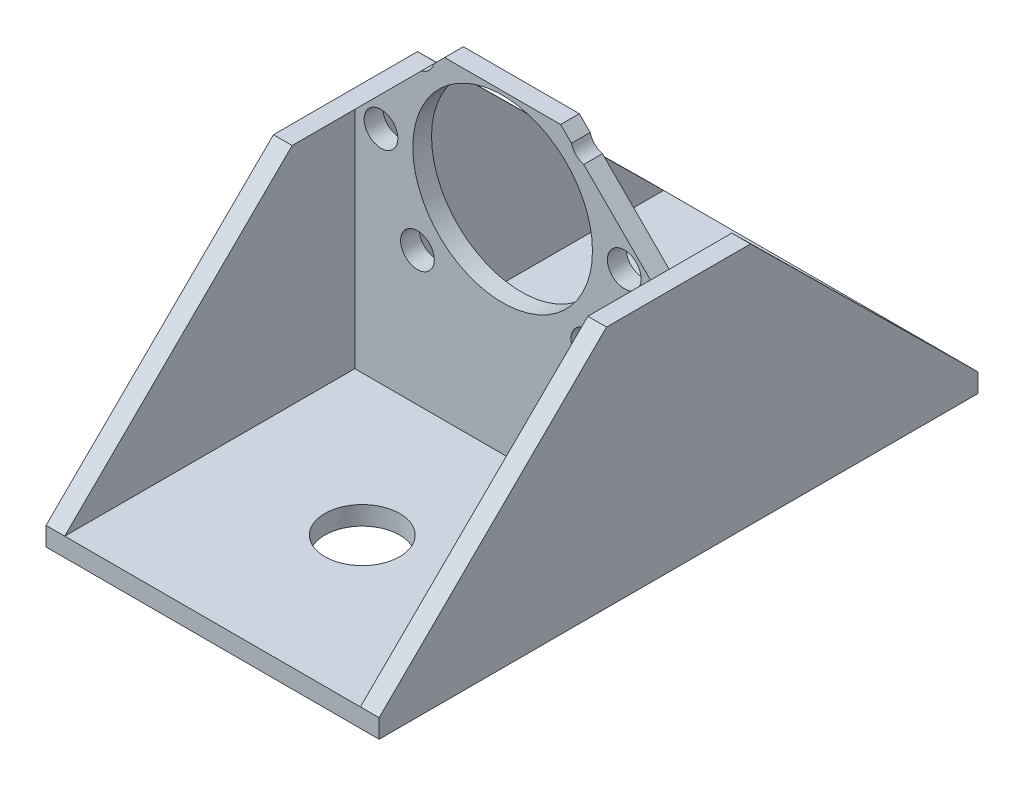
from build123d import *

# Parameters (mm, degrees)
CROQUIS1_W                   = 44.5
CROQUIS1_H                   = 44.5
CROQUIS1_W_2                 = 39.5
CROQUIS1_H_2                 = 39.5
SALIENTE_EXTRUIR1_DEPTH      = 40
SALIENTE_EXTRUIR1_DEPTH_BACK = 40
CORTAR_EXTRUIR1_DEPTH        = 44.5
SALIENTE_EXTRUIR2_DEPTH      = 1.25
SALIENTE_EXTRUIR2_DEPTH_BACK = 1.25
CROQUIS4_R                   = 5
CORTAR_EXTRUIR2_DEPTH        = 2.5
CROQUIS7_R                   = 12
CORTAR_EXTRUIR5_DEPTH        = 2.5
CROQUIS8_R                   = 2.25
CORTAR_EXTRUIR6_DEPTH        = 2.5


with BuildPart() as part:
    # Croquis1 → Saliente-Extruir1 (new body, two sides)
    with BuildSketch(Plane.XY) as saliente_extruir1_sk:
        Rectangle(CROQUIS1_W, CROQUIS1_H)
        Rectangle(CROQUIS1_W_2, CROQUIS1_H_2, mode=Mode.SUBTRACT)
    extrude(amount=SALIENTE_EXTRUIR1_DEPTH)
    extrude(saliente_extruir1_sk.sketch, amount=-SALIENTE_EXTRUIR1_DEPTH_BACK)

    # Croquis2 → Cortar-Extruir1 (cut)
    with BuildSketch(Plane(origin=(22.25, 0, 0), x_dir=(0, 0, -1), z_dir=(1, 0, 0))):
        Polygon((-9.620253165, 10.25), (9.620253165, 10.25), (40, -19.75), (40, 22.25), (-40, 22.25), (-40, -19.75), align=None)
    extrude(amount=-CORTAR_EXTRUIR1_DEPTH, mode=Mode.SUBTRACT)

    # Croquis3 → Saliente-Extruir2 (add, two sides)
    with BuildSketch(Plane.XY) as saliente_extruir2_sk:
        Polygon((19.75, -19.75), (19.75, 10.25), (7.75, 22.25), (-7.75, 22.25), (-19.75, 10.25), (-19.75, -19.75), align=None)
    extrude(amount=SALIENTE_EXTRUIR2_DEPTH)
    extrude(saliente_extruir2_sk.sketch, amount=-SALIENTE_EXTRUIR2_DEPTH_BACK)

    # Croquis4 → Cortar-Extruir2 (cut)
    with BuildSketch(Plane.XZ.offset(22.25)):
        with Locations((0, -20)):
            Circle(CROQUIS4_R)
        with Locations((0, 20)):
            Circle(CROQUIS4_R)
    extrude(amount=-CORTAR_EXTRUIR2_DEPTH, mode=Mode.SUBTRACT)

    # Croquis7 → Cortar-Extruir5 (cut)
    with BuildSketch(Plane.XY.offset(1.25)):
        with Locations((0, 9.75)):
            Circle(CROQUIS7_R)
    extrude(amount=-CORTAR_EXTRUIR5_DEPTH, mode=Mode.SUBTRACT)

    # Croquis8 → Cortar-Extruir6 (cut)
    with BuildSketch(Plane.XY.offset(1.25)):
        with Locations((-11.37991652, 21.35)):
            Circle(CROQUIS8_R)
        with Locations((11.37991652, 21.35)):
            Circle(CROQUIS8_R)
        with Locations((-16.25, 9.75)):
            Circle(CROQUIS8_R)
        with Locations((16.25, 9.75)):
            Circle(CROQUIS8_R)
        with Locations((-11.37991652, -1.85)):
            Circle(CROQUIS8_R)
        with Locations((11.37991652, -1.85)):
            Circle(CROQUIS8_R)
    extrude(amount=-CORTAR_EXTRUIR6_DEPTH, mode=Mode.SUBTRACT)


solid = part.part
